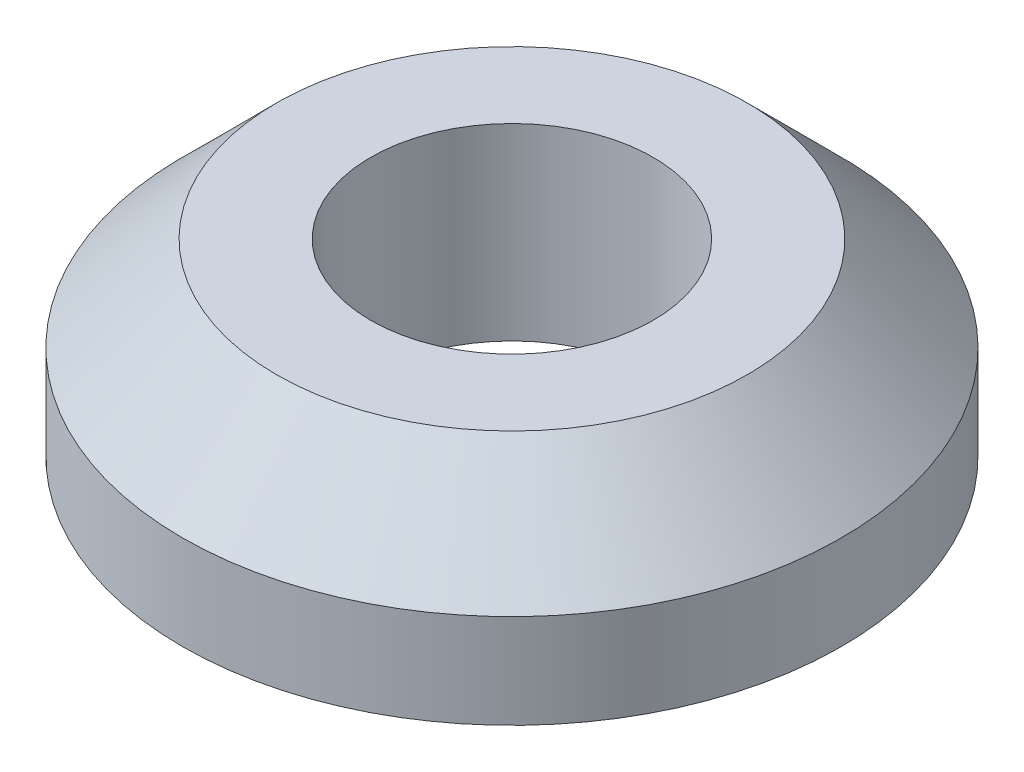
from build123d import *

# Parameters (mm, degrees)
SKETCH1_R           = 3.5
BOSS_EXTRUDE1_DEPTH = 2
SKETCH2_R           = 1.5
CUT_EXTRUDE1_DEPTH  = 2
CHAMFER1_SIZE       = 1


with BuildPart() as part:
    # Sketch1 → Boss-Extrude1 (new body)
    with BuildSketch(Plane(origin=(0, 0, 0), x_dir=(1, 0, 0), z_dir=(0, 1, 0))):
        Circle(SKETCH1_R)
    extrude(amount=BOSS_EXTRUDE1_DEPTH)

    # Sketch2 → Cut-Extrude1 (cut)
    with BuildSketch(Plane(origin=(0, 2, 0), x_dir=(1, 0, 0), z_dir=(0, 1, 0))):
        Circle(SKETCH2_R)
    extrude(amount=-CUT_EXTRUDE1_DEPTH, mode=Mode.SUBTRACT)

    # Chamfer1
    chamfer1_edges = [part.edges().sort_by_distance(p)[0] for p in [
        (-3.5, 2, 0),
    ]]
    chamfer(chamfer1_edges, length=CHAMFER1_SIZE)


solid = part.part
